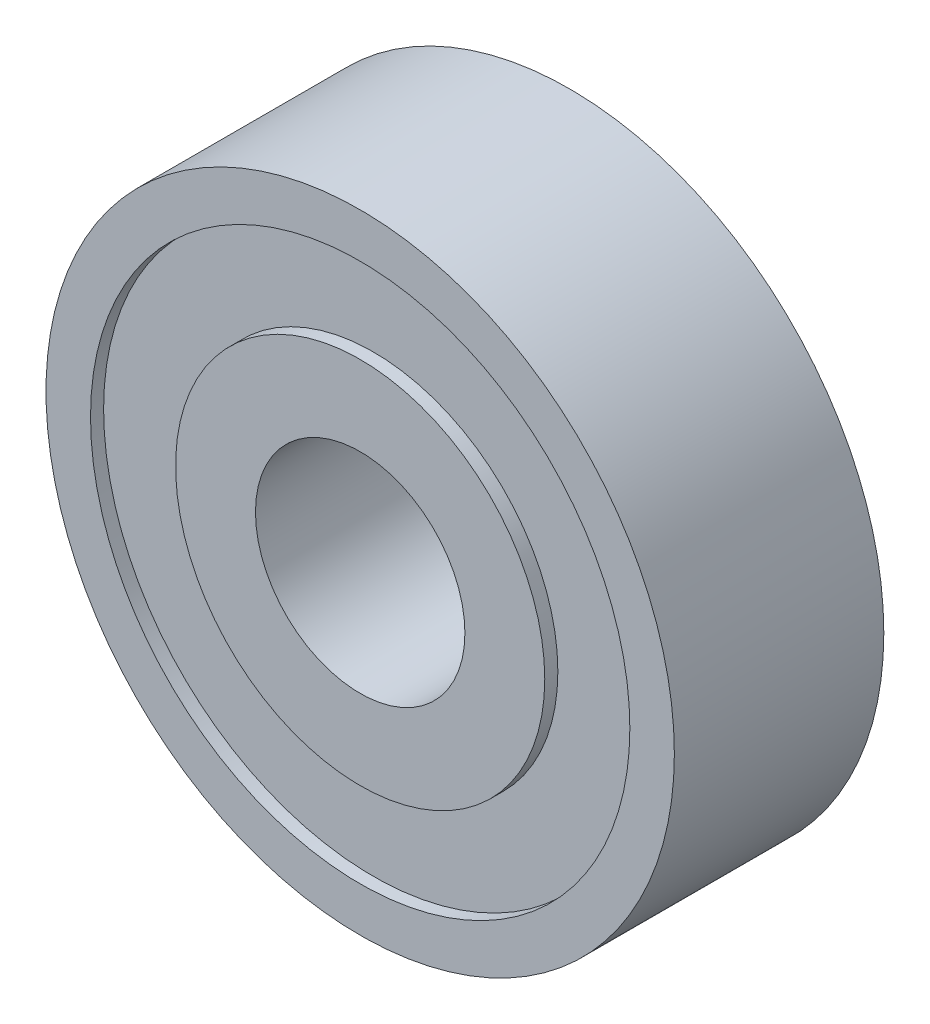
from build123d import *

# Parameters (mm, degrees)
SKETCH_1_R          = 12
EXTRUDE_1_DEPTH     = 4
SKETCH_2_R          = 4
CUT_EXTRUDE_1_DEPTH = 9
SKETCH_3_R          = 10.3
SKETCH_3_R_2        = 7.05
CUT_EXTRUDE_2_DEPTH = 0.5


with BuildPart() as part:
    # 草圖1 → 填料-伸長1 (new body, symmetric)
    with BuildSketch(Plane.XY):
        Circle(SKETCH_1_R)
    extrude(amount=EXTRUDE_1_DEPTH, both=True)

    # 草圖2 → 除料-伸長1 (cut, through all)
    with BuildSketch(Plane.XY.offset(4)):
        Circle(SKETCH_2_R)
    extrude(amount=-CUT_EXTRUDE_1_DEPTH, mode=Mode.SUBTRACT)

    # 草圖3 → 除料-伸長2 (cut)
    with BuildSketch(Plane.XY.offset(4)):
        Circle(SKETCH_3_R)
        Circle(SKETCH_3_R_2, mode=Mode.SUBTRACT)
    cut_extrude_2 = extrude(amount=-CUT_EXTRUDE_2_DEPTH, mode=Mode.SUBTRACT)

    # 鏡射1: 除料-伸長2 across plane
    add(cut_extrude_2.mirror(Plane.XY), mode=Mode.SUBTRACT)


solid = part.part
